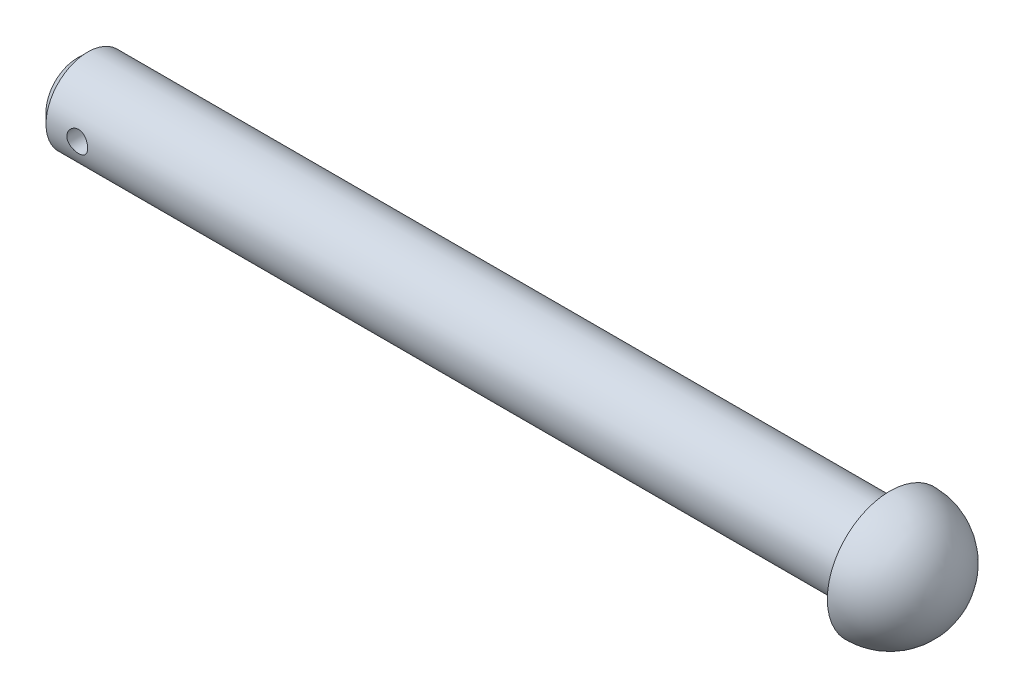
from build123d import *

# Parameters (mm, degrees)
SKETCH2_R               = 0.5
CUT_EXTRUDE1_DEPTH      = 4
CUT_EXTRUDE1_DEPTH_BACK = 4


with BuildPart() as part:
    # Sketch1 → Revolve1 (revolve)
    with BuildSketch(Plane.XY):
        with BuildLine():
            Line((0, 0), (0, 1.5))
            Line((0, 1.5), (0.5, 2))
            Line((0.5, 2), (39, 2))
            Line((39, 2), (39, 3))
            ThreePointArc((39, 3), (41.121320344, 2.121320344), (42, 0))
            Line((42, 0), (0, 0))
        make_face()
    revolve(axis=Axis((0, 0, 0), (1, 0, 0)))

    # Sketch2 → Cut-Extrude1 (cut, two sides)
    with BuildSketch(Plane.XY) as cut_extrude1_sk:
        with Locations((2, 0)):
            Circle(SKETCH2_R)
    extrude(amount=CUT_EXTRUDE1_DEPTH, mode=Mode.SUBTRACT)
    extrude(cut_extrude1_sk.sketch, amount=-CUT_EXTRUDE1_DEPTH_BACK, mode=Mode.SUBTRACT)


solid = part.part
